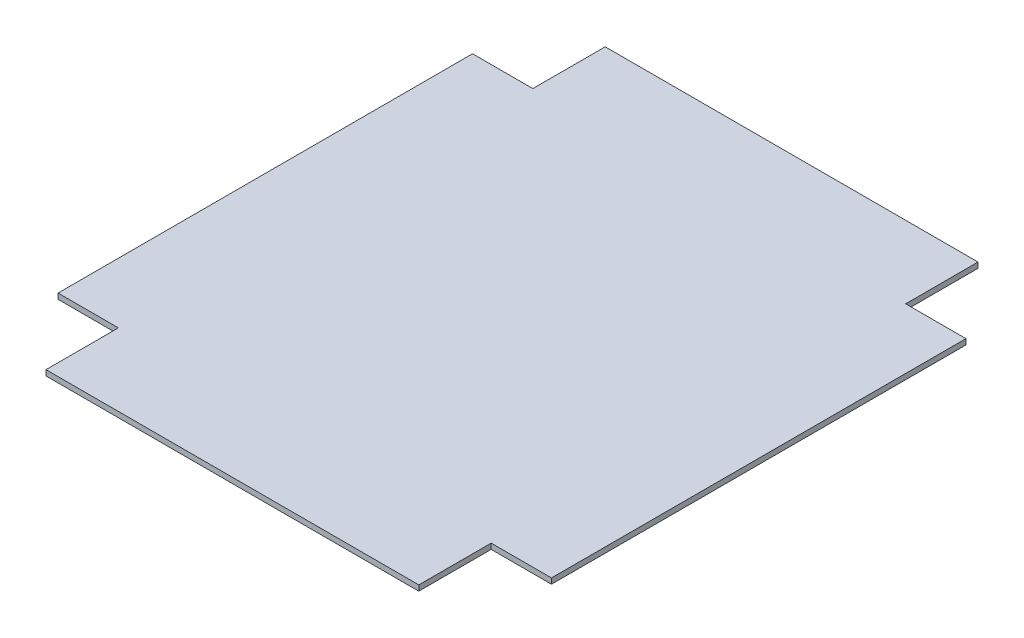
from build123d import *

# Parameters (mm, degrees)
BOSS_EXTRUDE1_DEPTH = 5


with BuildPart() as part:
    # Sketch1 → Boss-Extrude1 (new body)
    with BuildSketch(Plane(origin=(0, 0, 0), x_dir=(1, 0, 0), z_dir=(0, 1, 0))):
        Polygon((-170, 255), (170, 255), (170, 189), (225, 189), (225, -189), (170, -189), (170, -255), (-170, -255), (-170, -189), (-225, -189), (-225, 189), (-170, 189), align=None)
    extrude(amount=BOSS_EXTRUDE1_DEPTH)


solid = part.part
